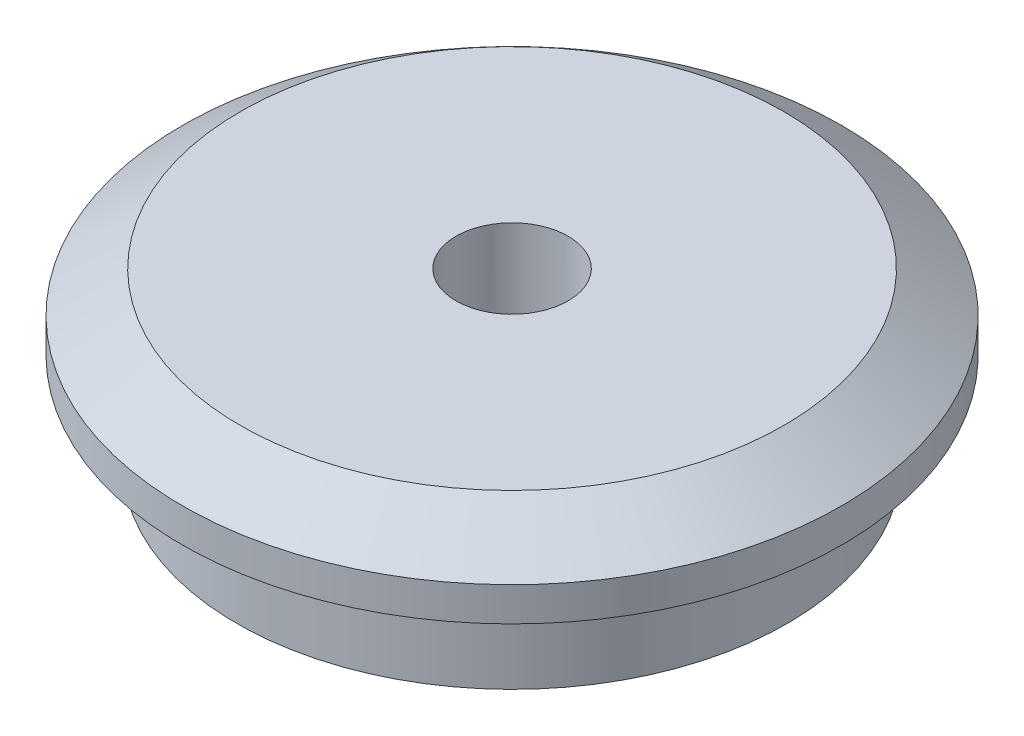
from build123d import *

# Parameters (mm, degrees)
SKETCH2_R          = 1.65
CUT_EXTRUDE1_DEPTH = 10


with BuildPart() as part:
    # Sketch1 → Revolve1 (revolve)
    with BuildSketch(Plane.XY):
        Polygon((0, 2.2), (6.9, 2.2), (6.9, 0), (8.1, 0), (8.1, 2.8), (9.7, 2.8), (9.7, 3.8), (8, 5), (0, 5), align=None)
    revolve(axis=Axis((0, 0, 0), (0, 1, 0)))

    # Sketch2 → Cut-Extrude1 (cut)
    with BuildSketch(Plane(origin=(0, 5, 0), x_dir=(1, 0, 0), z_dir=(0, 1, 0))):
        Circle(SKETCH2_R)
    extrude(amount=-CUT_EXTRUDE1_DEPTH, mode=Mode.SUBTRACT)


solid = part.part
